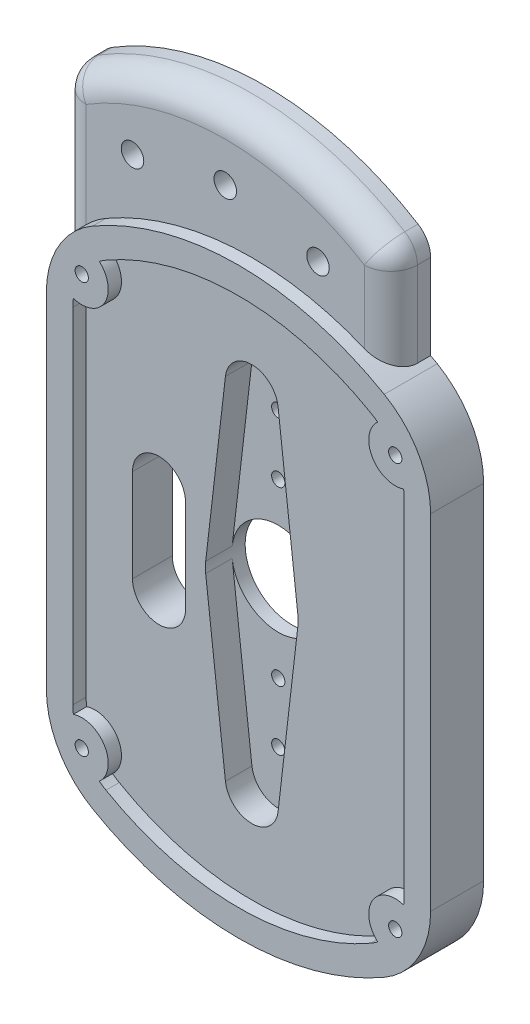
from build123d import *

# Parameters (mm, degrees)
EXTRUDE_1_DEPTH       = 6
SKETCH_1_3_R          = 1.0000000000000007
SKETCH_1_3_R_2        = 1.0000000000000009
EXTRUDE_2_DEPTH       = 2
SKETCH_1_4_R          = 1.0000000000000024
SKETCH_1_4_R_2        = 1.0000000000000022
SKETCH_1_4_R_3        = 0.9999999999999966
SKETCH_1_4_R_4        = 1.0000000000000009
EXTRUDE_3_DEPTH       = 8
CUT_EXTRUDE_1_DEPTH   = 54.0377224247045
EXTRUDE_4_DEPTH       = 6
FILLET_2_R            = 4
HOLE_WIZARD_M31_D     = 3.4
HOLE_WIZARD_M31_DEPTH = 13.978536948
HOLE_WIZARD_M31_TIP   = 1.0214630523468524


with BuildPart() as part:
    # Эскиз1 → Бобышка-Вытянуть1 (new body)
    with BuildSketch(Plane.XY):
        with BuildLine():
            Line((25.000000000000007, -25.98076211353316), (25.000000000000007, 25.980762113533153))
            ThreePointArc((25.000000000000007, 25.980762113533153), (24.981739705342804, 26.584808845817278), (24.927025509043382, 27.186649563837758))
            ThreePointArc((24.927025509043485, 27.18664956383775), (20.196152422706675, 28.98076211353309), (21.007841920590277, 33.974874663228555))
            ThreePointArc((21.007841920590295, 33.97487466322859), (20.513989667902422, 34.32317890618177), (20.000000000000014, 34.64101615137754))
            ThreePointArc((20.000000000000014, 34.64101615137754), (0, 40.00000000000001), (-20.000000000000018, 34.64101615137754))
            ThreePointArc((-20.000000000000014, 34.64101615137754), (-20.513989667902425, 34.32317890618177), (-21.0078419205903, 33.97487466322859))
            ThreePointArc((-21.00784192059028, 33.97487466322856), (-20.01267617924998, 32.62246116192532), (-19.660254037844396, 30.98076211353315))
            ThreePointArc((-19.660254037844396, 30.98076211353315), (-21.322208474216062, 27.735220102959588), (-24.92702550904333, 27.186649563837697))
            ThreePointArc((-24.92702550904339, 27.186649563837694), (-24.981739705342804, 26.584808845817246), (-25.000000000000007, 25.980762113533153))
            Line((-25.000000000000007, 25.980762113533153), (-25.000000000000007, -25.98076211353316))
            ThreePointArc((-25.000000000000007, -25.98076211353316), (-24.981739705342804, -26.584808845817253), (-24.92702550904339, -27.1866495638377))
            ThreePointArc((-24.927025509043325, -27.186649563837705), (-21.322208474216055, -27.735220102959595), (-19.66025403784439, -30.980762113533157))
            ThreePointArc((-19.66025403784439, -30.980762113533157), (-20.012676179249972, -32.62246116192533), (-21.007841920590273, -33.97487466322856))
            ThreePointArc((-21.007841920590288, -33.9748746632286), (-20.51398966790242, -34.32317890618177), (-20.00000000000001, -34.64101615137754))
            ThreePointArc((-20.00000000000001, -34.64101615137754), (8.9e-16, -40), (20.000000000000014, -34.64101615137754))
            ThreePointArc((20.00000000000001, -34.64101615137754), (20.51398966790242, -34.32317890618177), (21.007841920590288, -33.9748746632286))
            ThreePointArc((21.007841920590277, -33.97487466322857), (20.19615242270667, -28.980762113533096), (24.92702550904349, -27.18664956383776))
            ThreePointArc((24.927025509043382, -27.186649563837765), (24.981739705342804, -26.584808845817285), (25.000000000000007, -25.98076211353316))
        make_face()
        with BuildLine():
            ThreePointArc((-6.953246230078051, -0.8076923076923074), (-6.9999999999999964, -8e-17), (-6.953246230078052, 0.8076923076923072))
            Line((-6.953246230078053, 0.8076923076923073), (-3.9732835600445995, 26.46153846153846))
            ThreePointArc((-3.9732835600445995, 26.46153846153846), (1.61e-15, 30), (3.973283560044602, 26.46153846153846))
            Line((3.973283560044602, 26.46153846153846), (6.9532462300780535, 0.8076923076923066))
            ThreePointArc((6.9532462300780535, 0.8076923076923077), (6.988301782641701, 0.4045221807599798), (6.999999999999997, 0))
            ThreePointArc((6.999999999999997, 0), (6.988301782641701, -0.40452218075998), (6.9532462300780535, -0.8076923076923077))
            Line((6.9532462300780535, -0.8076923076923066), (3.973283560044602, -26.46153846153846))
            ThreePointArc((3.973283560044602, -26.46153846153846), (7.8e-16, -29.999999999999996), (-3.9732835600445995, -26.46153846153846))
            Line((-3.9732835600445995, -26.46153846153846), (-6.953246230078053, -0.8076923076923073))
        make_face(mode=Mode.SUBTRACT)
    extrude(amount=EXTRUDE_1_DEPTH)

    # Эскиз1<3> → Бобышка-Вытянуть2 (add)
    # profile 1 of 2: a face of its own
    with BuildSketch(Plane.XY):
        with BuildLine():
            Line((-3.9732835600445995, 26.46153846153846), (-6.953246230078053, 0.8076923076923073))
            ThreePointArc((-6.953246230078054, 0.8076923076923096), (1.98e-15, 7.000000000000001), (6.953246230078055, 0.8076923076923079))
            Line((6.9532462300780535, 0.8076923076923066), (3.973283560044602, 26.46153846153846))
            ThreePointArc((3.973283560044602, 26.46153846153846), (1.61e-15, 30), (-3.9732835600445995, 26.46153846153846))
        make_face()
        with Locations((0, 13)):
            Circle(SKETCH_1_3_R, mode=Mode.SUBTRACT)
        with Locations((0, 22)):
            Circle(SKETCH_1_3_R_2, mode=Mode.SUBTRACT)
    # profile 2 of 2: a face of its own
    with BuildSketch(Plane.XY):
        with BuildLine():
            ThreePointArc((6.953246230078054, -0.8076923076923105), (-1.29e-15, -7.000000000000001), (-6.953246230078055, -0.8076923076923079))
            Line((-6.953246230078053, -0.8076923076923073), (-3.9732835600445995, -26.46153846153846))
            ThreePointArc((-3.9732835600445995, -26.46153846153846), (7.8e-16, -29.999999999999996), (3.973283560044602, -26.46153846153846))
            Line((3.973283560044602, -26.46153846153846), (6.9532462300780535, -0.8076923076923066))
        make_face()
        with Locations((0, -22)):
            Circle(SKETCH_1_3_R_2, mode=Mode.SUBTRACT)
        with Locations((0, -13)):
            Circle(SKETCH_1_3_R, mode=Mode.SUBTRACT)
    extrude(amount=EXTRUDE_2_DEPTH)

    # Эскиз1<4> → Бобышка-Вытянуть3 (add)
    with BuildSketch(Plane.XY):
        with BuildLine():
            ThreePointArc((29.000000000000007, 25.980762113533153), (27.124355652982153, 32.98076211353315), (22.000000000000014, 38.10511776651529))
            ThreePointArc((22.000000000000014, 38.10511776651529), (-1.78e-15, 44), (-22.00000000000002, 38.10511776651529))
            ThreePointArc((-22.000000000000018, 38.10511776651529), (-27.124355652982153, 32.980762113533146), (-29.000000000000007, 25.98076211353315))
            Line((-29.000000000000007, 25.980762113533153), (-29.000000000000007, -25.98076211353316))
            ThreePointArc((-29.000000000000007, -25.98076211353316), (-27.124355652982146, -32.98076211353315), (-22.00000000000002, -38.10511776651529))
            ThreePointArc((-22.000000000000025, -38.10511776651529), (-6.22e-15, -44.00000000000001), (22.000000000000014, -38.1051177665153))
            ThreePointArc((22.000000000000014, -38.1051177665153), (27.124355652982153, -32.98076211353316), (29.00000000000001, -25.98076211353316))
            Line((29.000000000000007, -25.98076211353316), (29.00000000000001, 25.980762113533153))
        make_face()
        with BuildLine():
            ThreePointArc((24.927025509043382, 27.186649563837758), (24.981739705342804, 26.584808845817278), (25.000000000000007, 25.980762113533153))
            Line((25.000000000000007, 25.980762113533153), (25.000000000000007, -25.98076211353316))
            ThreePointArc((25.000000000000007, -25.98076211353316), (24.981739705342804, -26.584808845817285), (24.927025509043382, -27.186649563837765))
            ThreePointArc((24.92702550904349, -27.18664956383776), (20.19615242270667, -28.980762113533096), (21.007841920590277, -33.97487466322857))
            ThreePointArc((21.007841920590288, -33.9748746632286), (20.51398966790242, -34.32317890618177), (20.00000000000001, -34.64101615137754))
            ThreePointArc((20.000000000000014, -34.64101615137754), (8.9e-16, -40), (-20.00000000000001, -34.64101615137754))
            ThreePointArc((-20.00000000000001, -34.64101615137754), (-20.51398966790242, -34.32317890618177), (-21.007841920590288, -33.9748746632286))
            ThreePointArc((-21.00784192059027, -33.97487466322856), (-20.19615242270663, -28.980762113533167), (-24.927025509043325, -27.186649563837705))
            ThreePointArc((-24.92702550904339, -27.1866495638377), (-24.981739705342804, -26.584808845817253), (-25.000000000000007, -25.98076211353316))
            Line((-25.000000000000007, -25.98076211353316), (-25.000000000000007, 25.980762113533153))
            ThreePointArc((-25.000000000000007, 25.980762113533153), (-24.981739705342804, 26.584808845817246), (-24.92702550904339, 27.186649563837694))
            ThreePointArc((-24.92702550904333, 27.186649563837697), (-20.196152422706632, 28.980762113533164), (-21.00784192059028, 33.97487466322856))
            ThreePointArc((-21.0078419205903, 33.97487466322859), (-20.513989667902425, 34.32317890618177), (-20.000000000000014, 34.64101615137754))
            ThreePointArc((-20.000000000000018, 34.64101615137754), (0, 40.00000000000001), (20.000000000000014, 34.64101615137754))
            ThreePointArc((20.000000000000014, 34.64101615137754), (20.513989667902422, 34.32317890618177), (21.007841920590295, 33.97487466322859))
            ThreePointArc((21.007841920590277, 33.974874663228555), (20.196152422706675, 28.98076211353309), (24.927025509043485, 27.18664956383775))
        make_face(mode=Mode.SUBTRACT)
        with Locations((23.6602540378444, 30.98076211353315)):
            Circle(SKETCH_1_4_R, mode=Mode.SUBTRACT)
        with Locations((23.660254037844393, -30.980762113533157)):
            Circle(SKETCH_1_4_R_2, mode=Mode.SUBTRACT)
        with Locations((-23.660254037844393, 30.98076211353315)):
            Circle(SKETCH_1_4_R_3, mode=Mode.SUBTRACT)
        with Locations((-23.660254037844396, -30.98076211353316)):
            Circle(SKETCH_1_4_R_4, mode=Mode.SUBTRACT)
    extrude(amount=EXTRUDE_3_DEPTH)

    # Эскиз2 → Вырез-Вытянуть1 (cut, through all)
    with BuildSketch(Plane.XY.offset(6)):
        with BuildLine():
            Line((-17.998748741118916, -6.999248963798453), (-17.998748741118916, 7.000751036201546))
            ThreePointArc((-17.998748741118916, 7.000751036201546), (-13.99874874111892, 11.00075103620155), (-9.998748741118916, 7.0007510362015495))
            Line((-9.998748741118916, 7.0007510362015495), (-9.998748741118915, -6.999248963798453))
            ThreePointArc((-9.998748741118915, -6.999248963798453), (-13.998748741118916, -10.999248963798454), (-17.998748741118916, -6.999248963798453))
        make_face()
    extrude(amount=-CUT_EXTRUDE_1_DEPTH, mode=Mode.SUBTRACT)

    # Эскиз1<5> → Бобышка-Вытянуть4 (add)
    with BuildSketch(Plane.XY):
        with BuildLine():
            ThreePointArc((-22.00000000000002, 38.10511776651529), (-0.5730893375891295, 43.99626766682762), (21, 38.66522985836241))
            Line((20.999999999999996, 38.665229858362416), (20.999999999999986, 53.66522985836241))
            ThreePointArc((20.99999999999999, 53.665229858362416), (-4.000000000000013, 61.45749587789907), (-29.00000000000001, 53.665229858362416))
            Line((-29.000000000000007, 53.66522985836241), (-29.000000000000007, 25.980762113533153))
            ThreePointArc((-29.000000000000007, 25.980762113533153), (-28.522961473136743, 29.604229099178195), (-27.124355286277215, 32.98076274868469))
            ThreePointArc((-27.124355286277215, 32.98076274868469), (-24.89949467731214, 35.880257309444346), (-22.000000000000014, 38.10511776651529))
        make_face()
    extrude(amount=EXTRUDE_4_DEPTH)

    # Скругление2
    fillet_2_edges = [part.edges().sort_by_distance(p)[0] for p in [
        (-4.000000000000006, 61.45749587789908, 6),
        (20.999999999999993, 46.16522985836241, 6),
        (20.99999999999999, 53.665229858362416, 3),
        (-29.000000000000007, 53.665229858362416, 3),
        (-29.000000000000007, 39.822995985947784, 6),
    ]]
    fillet(fillet_2_edges, radius=FILLET_2_R)

    # Отверстие с зазором M31
    with Locations(Plane.XY.offset(6)):
        with Locations((-18, 48.441362648), (-4, 51.457495878), (10, 48.441362648)):
            Hole(HOLE_WIZARD_M31_D / 2, depth=HOLE_WIZARD_M31_DEPTH)
            with Locations((0, 0, -(HOLE_WIZARD_M31_DEPTH + HOLE_WIZARD_M31_TIP / 2))):  # 118° drill point
                Cone(0, HOLE_WIZARD_M31_D / 2, HOLE_WIZARD_M31_TIP, mode=Mode.SUBTRACT)


solid = part.part
